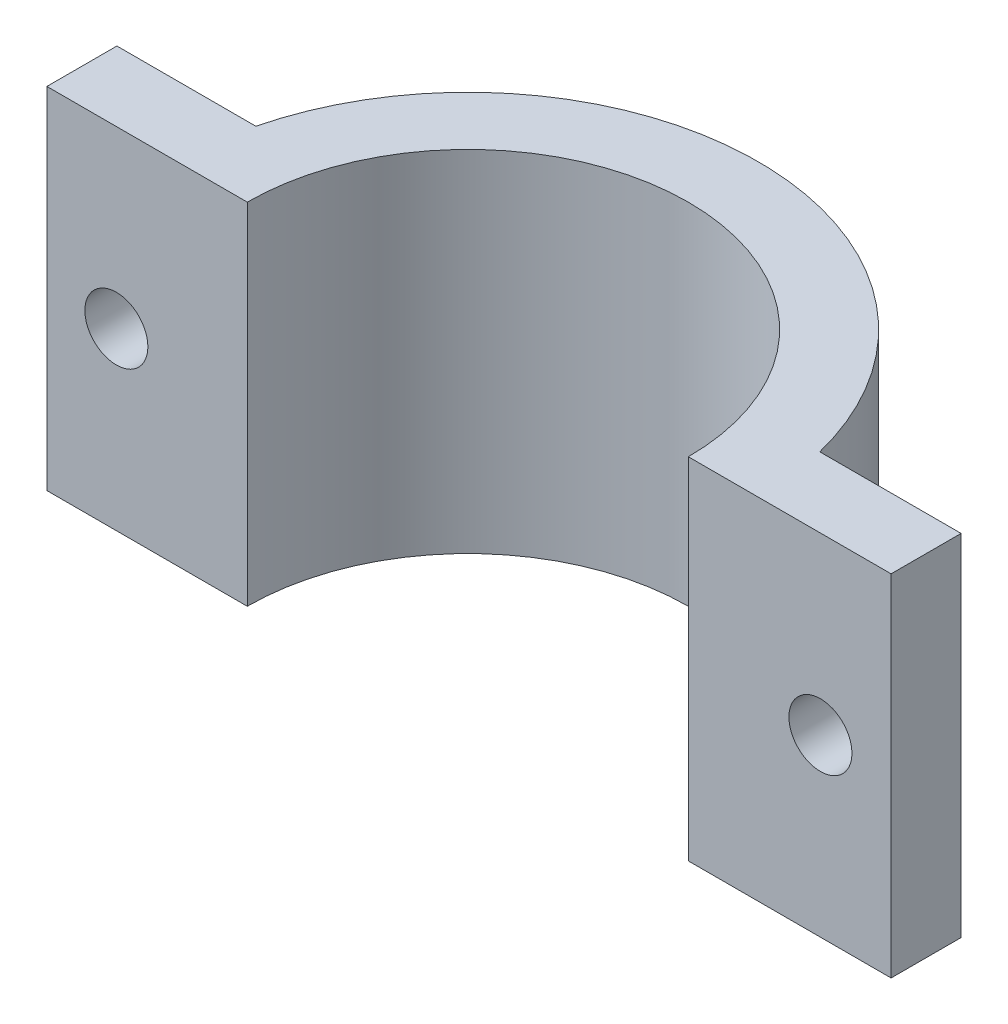
from build123d import *

# Parameters (mm, degrees)
BOSS_EXTRUDE1_DEPTH = 25.4
SKETCH2_R           = 2.286
CUT_EXTRUDE1_DEPTH  = 6.08


with BuildPart() as part:
    # Sketch1 → Boss-Extrude1 (new body)
    with BuildSketch(Plane(origin=(0, 0, 0), x_dir=(1, 0, 0), z_dir=(0, 1, 0))):
        with BuildLine():
            Line((-26.035, 0), (-16.002, 0))
            ThreePointArc((-16.002, 0), (0, 16.002), (16.002, 0))
            Line((16.002, 0), (26.035, 0))
            Line((26.035, 0), (30.716650549, 0))
            Line((30.716650549, 0), (30.716650549, 5.08))
            Line((30.716650549, 5.08), (26.035, 5.08))
            Line((26.035, 5.08), (20.460799691, 5.08))
            ThreePointArc((20.460799691, 5.08), (0, 21.082), (-20.460799691, 5.08))
            Line((-20.460799691, 5.08), (-26.035, 5.08))
            Line((-26.035, 5.08), (-30.543065264, 5.08))
            Line((-30.543065264, 5.08), (-30.543065264, 0))
            Line((-30.543065264, 0), (-26.035, 0))
        make_face()
    extrude(amount=BOSS_EXTRUDE1_DEPTH)

    # Sketch2 → Cut-Extrude1 (cut, through all)
    with BuildSketch(Plane(origin=(0, 0, -5.08), x_dir=(-1, 0, 0), z_dir=(0, 0, -1))):
        with Locations((-25.58872512, 12.7)):
            Circle(SKETCH2_R)
        with Locations((25.501932478, 12.7)):
            Circle(SKETCH2_R)
    extrude(amount=-CUT_EXTRUDE1_DEPTH, mode=Mode.SUBTRACT)


solid = part.part
